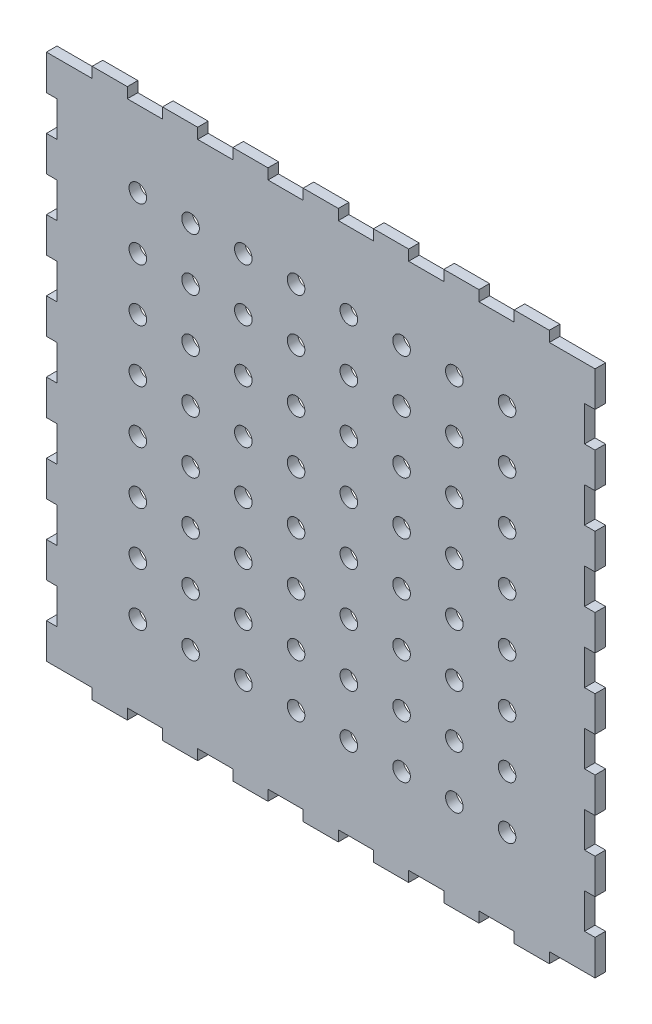
from build123d import *

# Parameters (mm, degrees)
SKETCH2_R           = 2.5
BOSS_EXTRUDE2_DEPTH = 3


with BuildPart() as part:
    # Sketch2 → Boss-Extrude2 (new body)
    with BuildSketch(Plane.XY):
        Polygon((156.230702788, -0.118374558), (153.230702788, -0.118374558), (143.230702788, -0.118374558), (143.230702788, -3.118374558), (133.230702788, -3.118374558), (133.230702788, -0.118374558), (123.230702788, -0.118374558), (123.230702788, -3.118374558), (113.230702788, -3.118374558), (113.230702788, -0.118374558), (103.230702788, -0.118374558), (103.230702788, -3.118374558), (93.230702788, -3.118374558), (93.230702788, -0.118374558), (83.230702788, -0.118374558), (83.230702788, -3.118374558), (73.230702788, -3.118374558), (73.230702788, -0.118374558), (63.230702788, -0.118374558), (63.230702788, -3.118374558), (53.230702788, -3.118374558), (53.230702788, -0.118374558), (43.230702788, -0.118374558), (43.230702788, -3.118374558), (33.230702788, -3.118374558), (33.230702788, -0.118374558), (23.230702788, -0.118374558), (23.230702788, -3.118374558), (13.230702788, -3.118374558), (13.230702788, -0.118374558), (3.230702788, -0.118374558), (0.230702788, -0.118374558), (0.230702788, 9.881625442), (3.230702788, 9.881625442), (3.230702788, 19.881625442), (0.230702788, 19.881625442), (0.230702788, 29.881625442), (3.230702788, 29.881625442), (3.230702788, 39.881625442), (0.230702788, 39.881625442), (0.230702788, 49.881625442), (3.230702788, 49.881625442), (3.230702788, 59.881625442), (0.230702788, 59.881625442), (0.230702788, 69.881625442), (3.230702788, 69.881625442), (3.230702788, 79.881625442), (0.230702788, 79.881625442), (0.230702788, 89.881625442), (3.230702788, 89.881625442), (3.230702788, 99.881625442), (0.230702788, 99.881625442), (0.230702788, 109.881625442), (3.230702788, 109.881625442), (3.230702788, 119.881625442), (0.230702788, 119.881625442), (0.230702788, 129.881625442), (3.230702788, 129.881625442), (3.230702788, 139.881625442), (0.230702788, 139.881625442), (0.230702788, 149.88750096), (3.230702788, 149.88750096), (13.230702788, 149.88750096), (13.230702788, 152.88750096), (23.230702788, 152.88750096), (23.230702788, 149.88750096), (33.230702788, 149.88750096), (33.230702788, 152.88750096), (43.230702788, 152.88750096), (43.230702788, 149.88750096), (53.230702788, 149.88750096), (53.230702788, 152.88750096), (63.230702788, 152.88750096), (63.230702788, 149.88750096), (73.230702788, 149.88750096), (73.230702788, 152.88750096), (83.230702788, 152.88750096), (83.230702788, 149.88750096), (93.230702788, 149.88750096), (93.230702788, 152.88750096), (103.230702788, 152.88750096), (103.230702788, 149.88750096), (113.230702788, 149.88750096), (113.230702788, 152.88750096), (123.230702788, 152.88750096), (123.230702788, 149.88750096), (133.230702788, 149.88750096), (133.230702788, 152.88750096), (143.230702788, 152.88750096), (143.230702788, 149.88750096), (153.230702788, 149.88750096), (156.230702788, 149.88750096), (156.230702788, 139.881625442), (153.230702788, 139.881625442), (153.230702788, 129.881625442), (156.230702788, 129.881625442), (156.230702788, 119.881625442), (153.230702788, 119.881625442), (153.230702788, 109.881625442), (156.230702788, 109.881625442), (156.230702788, 99.881625442), (153.230702788, 99.881625442), (153.230702788, 89.881625442), (156.230702788, 89.881625442), (156.230702788, 79.881625442), (153.230702788, 79.881625442), (153.230702788, 69.881625442), (156.230702788, 69.881625442), (156.230702788, 59.881625442), (153.230702788, 59.881625442), (153.230702788, 49.881625442), (156.230702788, 49.881625442), (156.230702788, 39.881625442), (153.230702788, 39.881625442), (153.230702788, 29.881625442), (156.230702788, 29.881625442), (156.230702788, 19.881625442), (153.230702788, 19.881625442), (153.230702788, 9.881625442), (156.230702788, 9.881625442), align=None)
        with Locations((26.219405474, 128.226120833)):
            Circle(SKETCH2_R, mode=Mode.SUBTRACT)
        with Locations((41.219405474, 128.226120833)):
            Circle(SKETCH2_R, mode=Mode.SUBTRACT)
        with Locations((56.219405474, 128.226120833)):
            Circle(SKETCH2_R, mode=Mode.SUBTRACT)
        with Locations((71.219405474, 128.226120833)):
            Circle(SKETCH2_R, mode=Mode.SUBTRACT)
        with Locations((86.219405474, 128.226120833)):
            Circle(SKETCH2_R, mode=Mode.SUBTRACT)
        with Locations((101.219405474, 128.226120833)):
            Circle(SKETCH2_R, mode=Mode.SUBTRACT)
        with Locations((116.219405474, 128.226120833)):
            Circle(SKETCH2_R, mode=Mode.SUBTRACT)
        with Locations((131.219405474, 128.226120833)):
            Circle(SKETCH2_R, mode=Mode.SUBTRACT)
        with Locations((26.219405474, 113.226120833)):
            Circle(SKETCH2_R, mode=Mode.SUBTRACT)
        with Locations((41.219405474, 113.226120833)):
            Circle(SKETCH2_R, mode=Mode.SUBTRACT)
        with Locations((56.219405474, 113.226120833)):
            Circle(SKETCH2_R, mode=Mode.SUBTRACT)
        with Locations((71.219405474, 113.226120833)):
            Circle(SKETCH2_R, mode=Mode.SUBTRACT)
        with Locations((86.219405474, 113.226120833)):
            Circle(SKETCH2_R, mode=Mode.SUBTRACT)
        with Locations((101.219405474, 113.226120833)):
            Circle(SKETCH2_R, mode=Mode.SUBTRACT)
        with Locations((116.219405474, 113.226120833)):
            Circle(SKETCH2_R, mode=Mode.SUBTRACT)
        with Locations((131.219405474, 113.226120833)):
            Circle(SKETCH2_R, mode=Mode.SUBTRACT)
        with Locations((26.219405474, 98.226120833)):
            Circle(SKETCH2_R, mode=Mode.SUBTRACT)
        with Locations((41.219405474, 98.226120833)):
            Circle(SKETCH2_R, mode=Mode.SUBTRACT)
        with Locations((56.219405474, 98.226120833)):
            Circle(SKETCH2_R, mode=Mode.SUBTRACT)
        with Locations((71.219405474, 98.226120833)):
            Circle(SKETCH2_R, mode=Mode.SUBTRACT)
        with Locations((86.219405474, 98.226120833)):
            Circle(SKETCH2_R, mode=Mode.SUBTRACT)
        with Locations((101.219405474, 98.226120833)):
            Circle(SKETCH2_R, mode=Mode.SUBTRACT)
        with Locations((116.219405474, 98.226120833)):
            Circle(SKETCH2_R, mode=Mode.SUBTRACT)
        with Locations((131.219405474, 98.226120833)):
            Circle(SKETCH2_R, mode=Mode.SUBTRACT)
        with Locations((26.219405474, 83.226120833)):
            Circle(SKETCH2_R, mode=Mode.SUBTRACT)
        with Locations((41.219405474, 83.226120833)):
            Circle(SKETCH2_R, mode=Mode.SUBTRACT)
        with Locations((56.219405474, 83.226120833)):
            Circle(SKETCH2_R, mode=Mode.SUBTRACT)
        with Locations((71.219405474, 83.226120833)):
            Circle(SKETCH2_R, mode=Mode.SUBTRACT)
        with Locations((86.219405474, 83.226120833)):
            Circle(SKETCH2_R, mode=Mode.SUBTRACT)
        with Locations((101.219405474, 83.226120833)):
            Circle(SKETCH2_R, mode=Mode.SUBTRACT)
        with Locations((116.219405474, 83.226120833)):
            Circle(SKETCH2_R, mode=Mode.SUBTRACT)
        with Locations((131.219405474, 83.226120833)):
            Circle(SKETCH2_R, mode=Mode.SUBTRACT)
        with Locations((26.219405474, 68.226120833)):
            Circle(SKETCH2_R, mode=Mode.SUBTRACT)
        with Locations((41.219405474, 68.226120833)):
            Circle(SKETCH2_R, mode=Mode.SUBTRACT)
        with Locations((56.219405474, 68.226120833)):
            Circle(SKETCH2_R, mode=Mode.SUBTRACT)
        with Locations((71.219405474, 68.226120833)):
            Circle(SKETCH2_R, mode=Mode.SUBTRACT)
        with Locations((86.219405474, 68.226120833)):
            Circle(SKETCH2_R, mode=Mode.SUBTRACT)
        with Locations((101.219405474, 68.226120833)):
            Circle(SKETCH2_R, mode=Mode.SUBTRACT)
        with Locations((116.219405474, 68.226120833)):
            Circle(SKETCH2_R, mode=Mode.SUBTRACT)
        with Locations((131.219405474, 68.226120833)):
            Circle(SKETCH2_R, mode=Mode.SUBTRACT)
        with Locations((26.219405474, 53.226120833)):
            Circle(SKETCH2_R, mode=Mode.SUBTRACT)
        with Locations((41.219405474, 53.226120833)):
            Circle(SKETCH2_R, mode=Mode.SUBTRACT)
        with Locations((56.219405474, 53.226120833)):
            Circle(SKETCH2_R, mode=Mode.SUBTRACT)
        with Locations((71.219405474, 53.226120833)):
            Circle(SKETCH2_R, mode=Mode.SUBTRACT)
        with Locations((86.219405474, 53.226120833)):
            Circle(SKETCH2_R, mode=Mode.SUBTRACT)
        with Locations((101.219405474, 53.226120833)):
            Circle(SKETCH2_R, mode=Mode.SUBTRACT)
        with Locations((116.219405474, 53.226120833)):
            Circle(SKETCH2_R, mode=Mode.SUBTRACT)
        with Locations((131.219405474, 53.226120833)):
            Circle(SKETCH2_R, mode=Mode.SUBTRACT)
        with Locations((26.219405474, 38.226120833)):
            Circle(SKETCH2_R, mode=Mode.SUBTRACT)
        with Locations((41.219405474, 38.226120833)):
            Circle(SKETCH2_R, mode=Mode.SUBTRACT)
        with Locations((56.219405474, 38.226120833)):
            Circle(SKETCH2_R, mode=Mode.SUBTRACT)
        with Locations((71.219405474, 38.226120833)):
            Circle(SKETCH2_R, mode=Mode.SUBTRACT)
        with Locations((86.219405474, 38.226120833)):
            Circle(SKETCH2_R, mode=Mode.SUBTRACT)
        with Locations((101.219405474, 38.226120833)):
            Circle(SKETCH2_R, mode=Mode.SUBTRACT)
        with Locations((116.219405474, 38.226120833)):
            Circle(SKETCH2_R, mode=Mode.SUBTRACT)
        with Locations((131.219405474, 38.226120833)):
            Circle(SKETCH2_R, mode=Mode.SUBTRACT)
        with Locations((26.219405474, 23.226120833)):
            Circle(SKETCH2_R, mode=Mode.SUBTRACT)
        with Locations((41.219405474, 23.226120833)):
            Circle(SKETCH2_R, mode=Mode.SUBTRACT)
        with Locations((56.219405474, 23.226120833)):
            Circle(SKETCH2_R, mode=Mode.SUBTRACT)
        with Locations((71.219405474, 23.226120833)):
            Circle(SKETCH2_R, mode=Mode.SUBTRACT)
        with Locations((86.219405474, 23.226120833)):
            Circle(SKETCH2_R, mode=Mode.SUBTRACT)
        with Locations((101.219405474, 23.226120833)):
            Circle(SKETCH2_R, mode=Mode.SUBTRACT)
        with Locations((116.219405474, 23.226120833)):
            Circle(SKETCH2_R, mode=Mode.SUBTRACT)
        with Locations((131.219405474, 23.226120833)):
            Circle(SKETCH2_R, mode=Mode.SUBTRACT)
    extrude(amount=BOSS_EXTRUDE2_DEPTH)


solid = part.part
